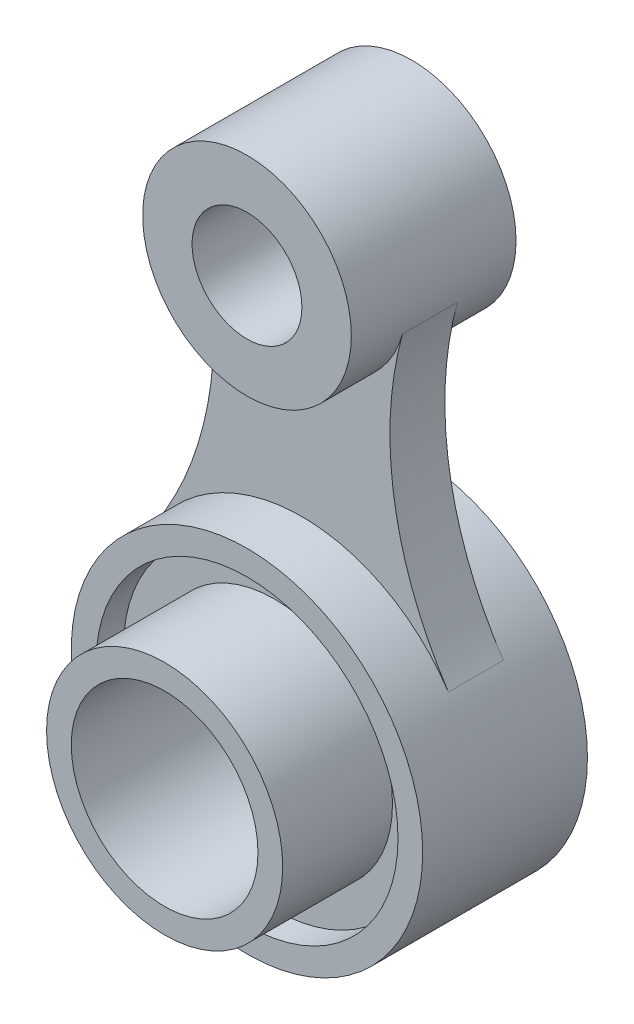
from build123d import *

# Parameters (mm, degrees)
BOSS_EXTRU_1_DEPTH      = 5
ESQUISSE1_3_R           = 10
BOSS_EXTRU_2_DEPTH      = 15
BOSS_EXTRU_3_DEPTH      = 30
BOSS_EXTRU_3_DEPTH_BACK = 15
ESQUISSE1_5_R           = 21.5
ESQUISSE1_5_R_2         = 17
ESQUISSE1_6_R           = 32
ESQUISSE1_6_R_2         = 21.5
BOSS_EXTRU_4_DEPTH      = 15
ENL_V_START             = 10
ESQUISSE1_7_R           = 27.5
ESQUISSE1_7_R_2         = 21.5
ENL_V_MAT_EXTRU_1_DEPTH = 5


with BuildPart() as part:
    # Esquisse1 → Boss.-Extru.1 (new, symmetric)
    with BuildSketch(Plane.XY):
        with BuildLine():
            ThreePointArc((-26.678302647, 17.671111111), (0, 32), (26.678302647, 17.671111111))
            ThreePointArc((26.678302647, 17.671111111), (16.836772686, 42.914041255), (18.321243986, 69.966907631))
            ThreePointArc((18.321243986, 69.966907631), (0, 56), (-18.321243986, 69.966907631))
            ThreePointArc((-18.321243986, 69.966907631), (-16.836772686, 42.914041255), (-26.678302647, 17.671111111))
        make_face()
    extrude(amount=BOSS_EXTRU_1_DEPTH, both=True)

    # Esquisse1_3 → Boss.-Extru.2 (add, symmetric)
    with BuildSketch(Plane.XY):
        with BuildLine():
            ThreePointArc((-18.321243986, 69.966907631), (0, 56), (18.321243986, 69.966907631))
            ThreePointArc((18.321243986, 69.966907631), (18.829546406, 72.460672898), (19, 75))
            ThreePointArc((19, 75), (-2.539327102, 93.829546406), (-18.321243986, 69.966907631))
        make_face()
        with Locations((0, 75)):
            Circle(ESQUISSE1_3_R, mode=Mode.SUBTRACT)
    extrude(amount=BOSS_EXTRU_2_DEPTH, both=True)



with BuildPart() as body_2:
    # Esquisse1_5 → Boss.-Extru.3 (new, two sides: drawn at the far end of the back side and taken through both)
    with BuildSketch(Plane.XY.offset(-BOSS_EXTRU_3_DEPTH_BACK)):
        Circle(ESQUISSE1_5_R)
        Circle(ESQUISSE1_5_R_2, mode=Mode.SUBTRACT)
    extrude(amount=BOSS_EXTRU_3_DEPTH + BOSS_EXTRU_3_DEPTH_BACK)


with BuildPart() as part_1:
    add(part.part)

    add(body_2.part)  # Boss.-Extru.4 merges body 2
    # Esquisse1_6 → Boss.-Extru.4 (add, symmetric)
    with BuildSketch(Plane.XY):
        Circle(ESQUISSE1_6_R)
        Circle(ESQUISSE1_6_R_2, mode=Mode.SUBTRACT)
    extrude(amount=BOSS_EXTRU_4_DEPTH, both=True)

    # Esquisse1_7 → Enl_v. mat.-Extru.1 (cut)
    with BuildSketch(Plane.XY.offset(ENL_V_START)):
        Circle(ESQUISSE1_7_R)
        Circle(ESQUISSE1_7_R_2, mode=Mode.SUBTRACT)
    extrude(amount=ENL_V_MAT_EXTRU_1_DEPTH, mode=Mode.SUBTRACT)


solid = part_1.part
